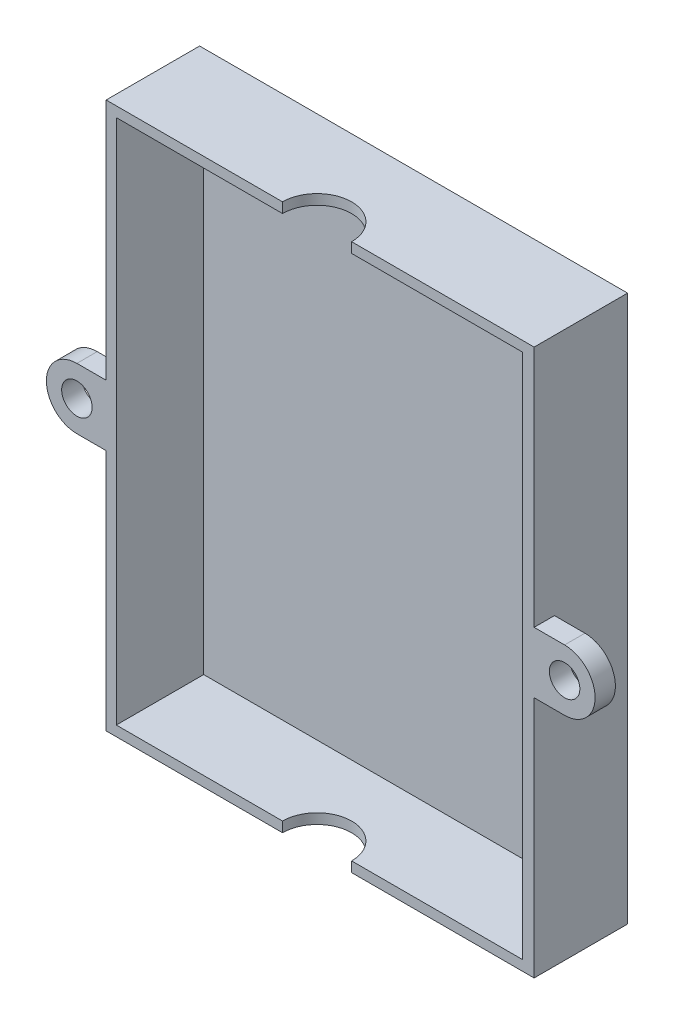
from build123d import *

# Parameters (mm, degrees)
SKETCH2_W                = 200
SKETCH2_H                = 258.87959476
BOSS_EXTRUDE1_DEPTH      = 3
SKETCH6_W                = 200
SKETCH6_H                = 258.87959476
BOSS_EXTRUDE2_DEPTH      = 43
BOSS_EXTRUDE2_DEPTH_BACK = 3
SKETCH7_R                = 17
CUT_EXTRUDE1_DEPTH       = 1
CUT_EXTRUDE1_DEPTH_BACK  = 269.87959476
SKETCH9_R                = 7.5
BOSS_EXTRUDE3_DEPTH      = 10


with BuildPart() as part:
    # Sketch2 → Boss-Extrude1 (new body)
    with BuildSketch(Plane(origin=(0, 0, 0), x_dir=(-1, 0, 0), z_dir=(0, 0, 1))):
        with Locations((-1.649083583, 6.704740248)):
            Rectangle(SKETCH2_W, SKETCH2_H)
    extrude(amount=BOSS_EXTRUDE1_DEPTH)

    # Sketch6 → Boss-Extrude2 (add, two sides)
    with BuildSketch(Plane.XY.offset(3)) as boss_extrude2_sk:
        Polygon((-98.350916417, 127.735057132), (-103.350916417, 127.735057132), (-103.350916417, 122.735057132), (-103.350916417, -141.144537628), (107.252666614, -141.144537628), (107.252666614, 127.735057132), align=None)
        with Locations((1.649083583, -6.704740248)):
            Rectangle(SKETCH6_W, SKETCH6_H, mode=Mode.SUBTRACT)
    extrude(amount=BOSS_EXTRUDE2_DEPTH)
    extrude(boss_extrude2_sk.sketch, amount=-BOSS_EXTRUDE2_DEPTH_BACK)

    # Sketch7 → Cut-Extrude1 (cut, two sides)
    with BuildSketch(Plane.XZ.offset(141.144537628)) as cut_extrude1_sk:
        with Locations((0.452666614, 46)):
            Circle(SKETCH7_R)
    extrude(amount=CUT_EXTRUDE1_DEPTH, mode=Mode.SUBTRACT)
    extrude(cut_extrude1_sk.sketch, amount=-CUT_EXTRUDE1_DEPTH_BACK, mode=Mode.SUBTRACT)

    # Sketch9 → Boss-Extrude3 (add)
    with BuildSketch(Plane.XY.offset(46)):
        with BuildLine():
            Line((107.252666614, 8.295259752), (107.252666614, -6.704740248))
            Line((107.252666614, -6.704740248), (107.252666614, -21.704740248))
            Line((107.252666614, -21.704740248), (122.252666614, -21.704740248))
            ThreePointArc((122.252666614, -21.704740248), (137.252666614, -6.704740248), (122.252666614, 8.295259752))
            Line((122.252666614, 8.295259752), (107.252666614, 8.295259752))
        make_face()
        with Locations((122.252666614, -6.704740248)):
            Circle(SKETCH9_R, mode=Mode.SUBTRACT)
        with BuildLine():
            Line((-102.747333386, -21.704740248), (-102.747333386, -6.704740248))
            Line((-102.747333386, -6.704740248), (-102.747333386, 8.295259752))
            Line((-102.747333386, 8.295259752), (-117.747333386, 8.295259752))
            ThreePointArc((-117.747333386, 8.295259752), (-132.747333386, -6.704740248), (-117.747333386, -21.704740248))
            Line((-117.747333386, -21.704740248), (-102.747333386, -21.704740248))
        make_face()
        with Locations((-117.747333386, -6.704740248)):
            Circle(SKETCH9_R, mode=Mode.SUBTRACT)
    extrude(amount=-BOSS_EXTRUDE3_DEPTH)


solid = part.part
